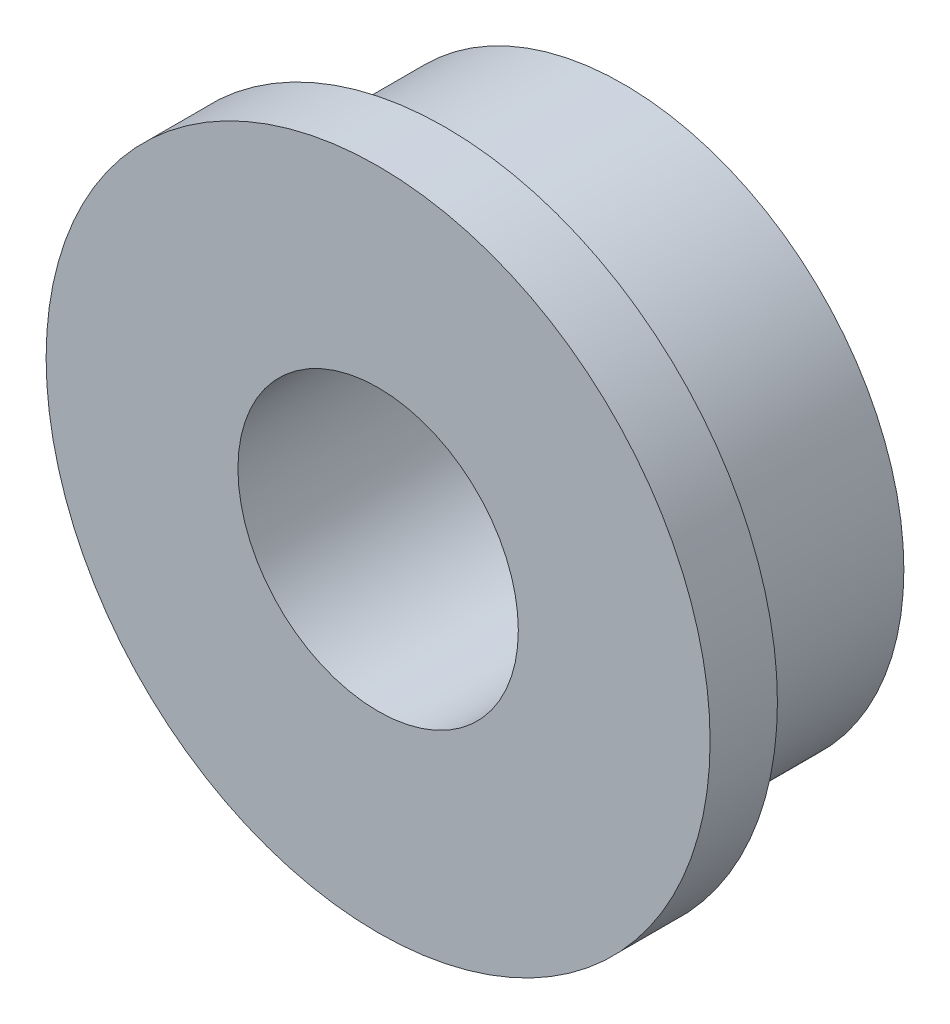
from build123d import *

# Parameters (mm, degrees)
SKETCH1_R           = 3.175
SKETCH1_R_2         = 1.5875
BOSS_EXTRUDE1_DEPTH = 2.016125
SKETCH2_R           = 3.7592
SKETCH2_R_2         = 1.5875
BOSS_EXTRUDE2_DEPTH = 0.762


with BuildPart() as part:
    # Sketch1 → Boss-Extrude1 (new body)
    with BuildSketch(Plane.XY):
        Circle(SKETCH1_R)
        Circle(SKETCH1_R_2, mode=Mode.SUBTRACT)
    extrude(amount=BOSS_EXTRUDE1_DEPTH)

    # Sketch2 → Boss-Extrude2 (add)
    with BuildSketch(Plane.XY.offset(2.016125)):
        Circle(SKETCH2_R)
        Circle(SKETCH2_R_2, mode=Mode.SUBTRACT)
    extrude(amount=BOSS_EXTRUDE2_DEPTH)


solid = part.part
